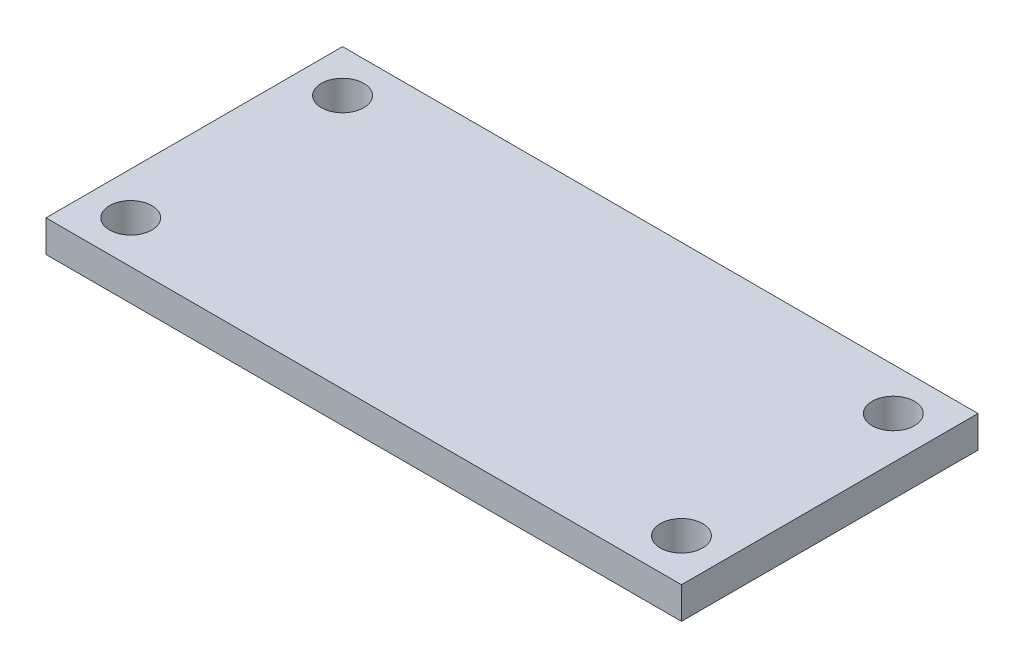
from build123d import *

# Parameters (mm, degrees)
SKETCH2_W           = 60
SKETCH2_H           = 28
BOSS_EXTRUDE1_DEPTH = 3
SKETCH3_R           = 2
CUT_EXTRUDE1_DEPTH  = 4


with BuildPart() as part:
    # Sketch2 → Boss-Extrude1 (new body)
    with BuildSketch(Plane(origin=(0, 0, 0), x_dir=(1, 0, 0), z_dir=(0, 1, 0))):
        with Locations((30, 14)):
            Rectangle(SKETCH2_W, SKETCH2_H)
    extrude(amount=BOSS_EXTRUDE1_DEPTH)

    # Sketch3 → Cut-Extrude1 (cut, through all)
    with BuildSketch(Plane(origin=(0, 3, 0), x_dir=(1, 0, 0), z_dir=(0, 1, 0))):
        with Locations((4, 4)):
            Circle(SKETCH3_R)
        with Locations((4, 24)):
            Circle(SKETCH3_R)
        with Locations((56, 24)):
            Circle(SKETCH3_R)
        with Locations((56, 4)):
            Circle(SKETCH3_R)
    extrude(amount=-CUT_EXTRUDE1_DEPTH, mode=Mode.SUBTRACT)


solid = part.part
